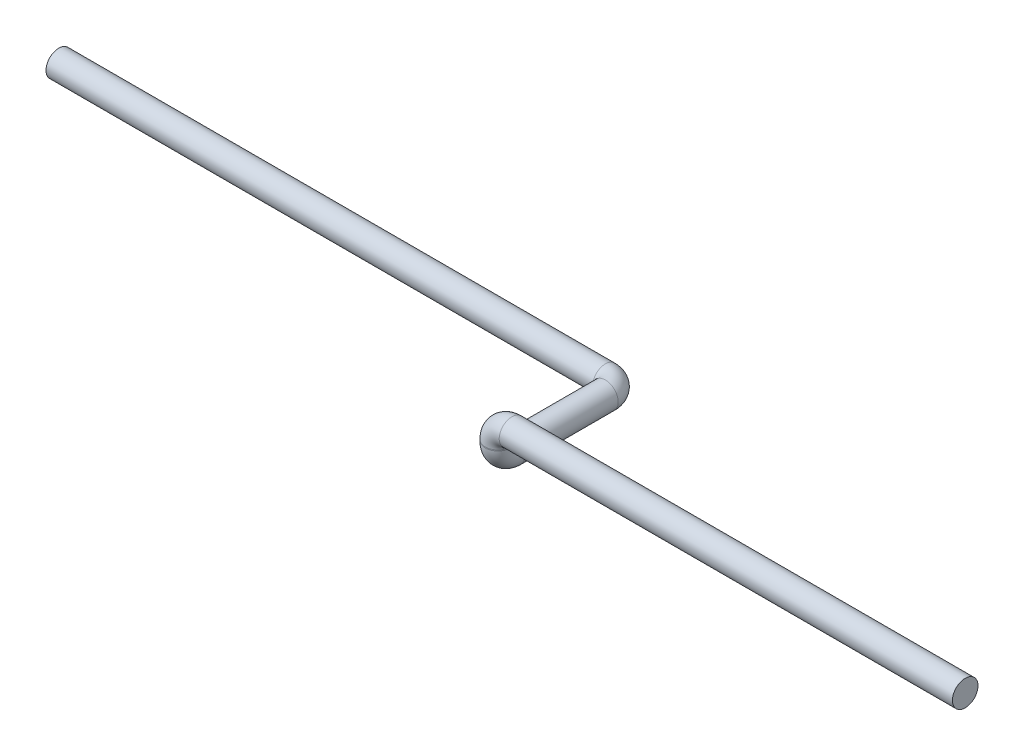
from build123d import *

# Parameters (mm, degrees)
CROQUIS1_R = 13.7


with BuildPart() as part:
    # Barrer1: sweep along a curve in space
    with BuildLine() as barrer1_path:
        Line((0, 0, 0), (-485, 0, 0))
        ThreePointArc((-485, 0, 0), (-495.606601718, -4.393398282, 0), (-500, -15, 0))
        Line((-500, -15, 0), (-500, -16, 0))
        ThreePointArc((-500, -16, 0), (-500, -26.606601718, -4.393398282), (-500, -31, -15))
        Line((-500, -31, -15), (-500, -31, -115))
        ThreePointArc((-500, -31, -115), (-504.393398282, -31, -125.606601718), (-515, -31, -130))
        Line((-515, -31, -130), (-1100, -31, -130))
    # Croquis1 → Barrer1 (sweep)
    with BuildSketch(Plane(origin=(0, 0, 0), x_dir=(0, 0, -1), z_dir=(1, 0, 0))):
        Circle(CROQUIS1_R)
    sweep(path=barrer1_path.line)


solid = part.part
